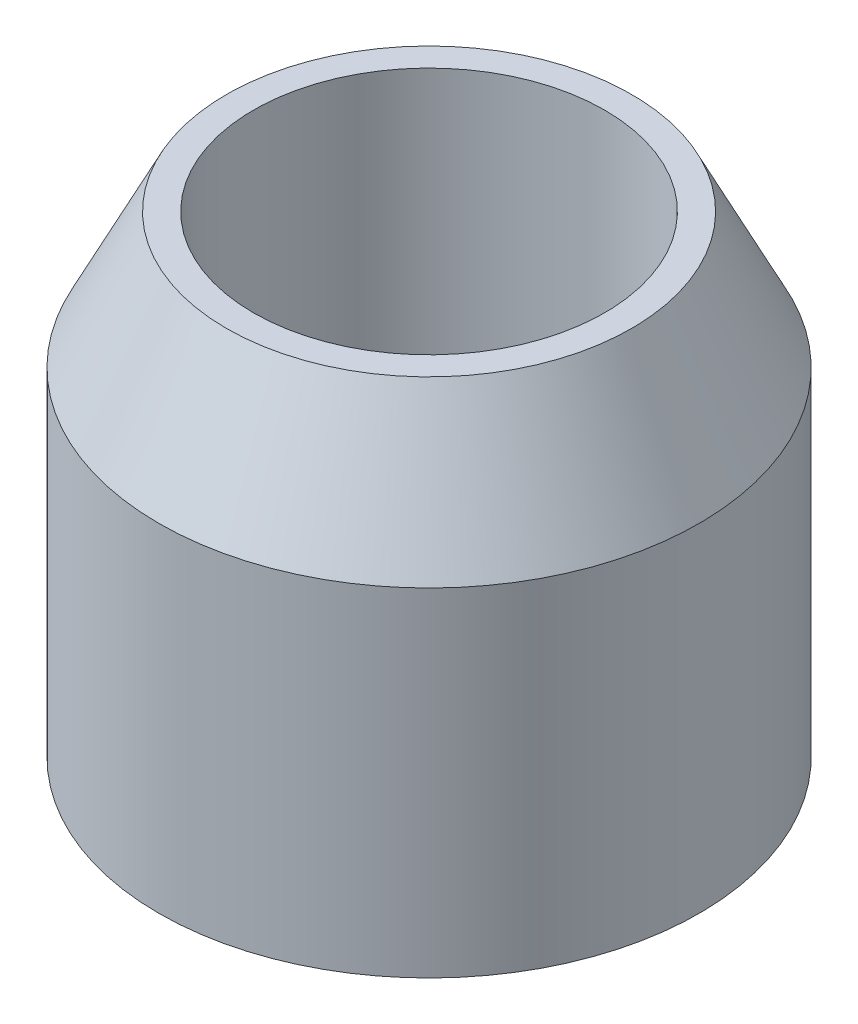
from build123d import *

# Parameters (mm, degrees)
SKETCH1_R      = 4
SKETCH1_R_2    = 2.6
EXTRUDE1_DEPTH = 7
CHAMFER1_SIZE  = 2
CHAMFER1_SIZE2 = 1


with BuildPart() as part:
    # Sketch1 → Extrude1 (new body)
    with BuildSketch(Plane(origin=(0, 0, 0), x_dir=(1, 0, 0), z_dir=(0, 1, 0))):
        Circle(SKETCH1_R)
        Circle(SKETCH1_R_2, mode=Mode.SUBTRACT)
    extrude(amount=EXTRUDE1_DEPTH)

    # Chamfer1
    chamfer1_edges = [part.edges().sort_by_distance(p)[0] for p in [
        (-4, 7, 0),
    ]]
    chamfer1_side = [part.faces().sort_by_distance(p)[0] for p in [
        (-4, 3.5, 0),
    ]]
    chamfer(chamfer1_edges, length=CHAMFER1_SIZE, length2=CHAMFER1_SIZE2, reference=chamfer1_side[0])


solid = part.part
